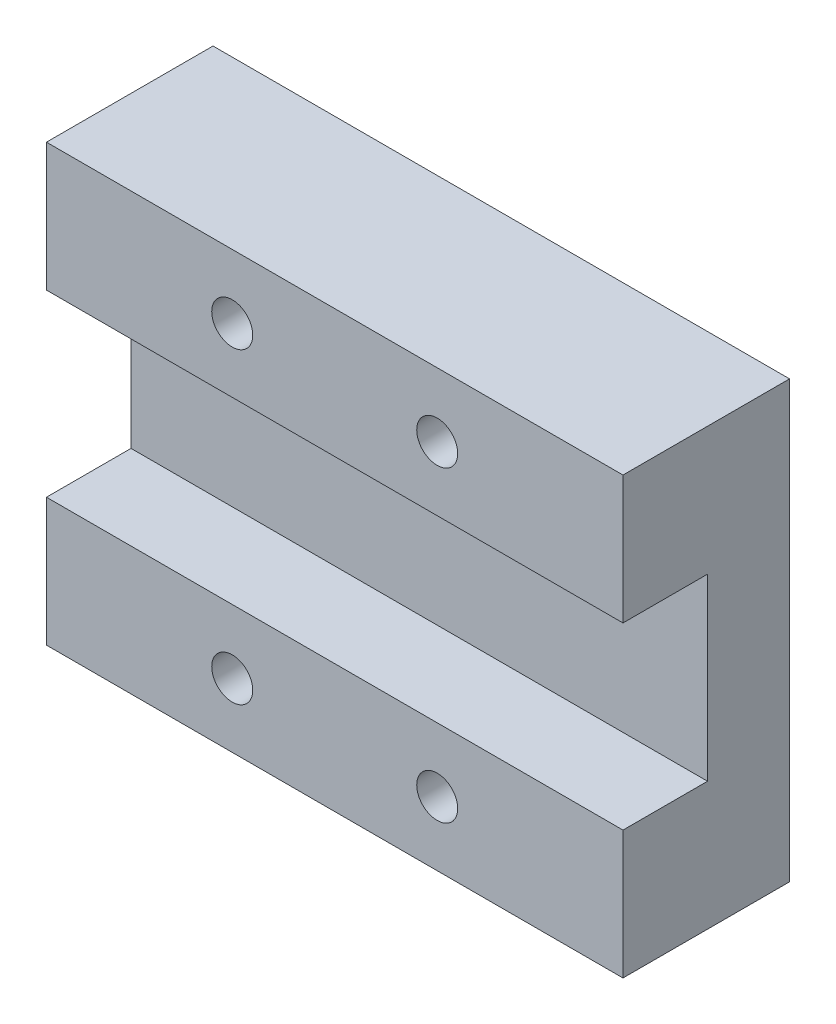
from build123d import *

# Parameters (mm, degrees)
SKETCH_1_W             = 22.5
SKETCH_1_H             = 17
EXTRUDE_1_DEPTH        = 6.5
SKETCH_2_W             = 3.3
SKETCH_2_H             = 7
CUT_EXTRUDE_1_DEPTH    = 23.5
HOLE_WIZARD_M2_1_D     = 1.6
HOLE_WIZARD_M2_1_DEPTH = 10.1
HOLE_WIZARD_M2_1_TIP   = 0.480688495


with BuildPart() as part:
    # 草图1 → 凸台-拉伸1 (new body)
    with BuildSketch(Plane.XY):
        with Locations((11.25, 8.5)):
            Rectangle(SKETCH_1_W, SKETCH_1_H)
    extrude(amount=EXTRUDE_1_DEPTH)

    # 草图2 → 切除-拉伸1 (cut, through all)
    with BuildSketch(Plane.ZY):
        with Locations((4.85, 8.5)):
            Rectangle(SKETCH_2_W, SKETCH_2_H)
    extrude(amount=-CUT_EXTRUDE_1_DEPTH, mode=Mode.SUBTRACT)

    # M2 螺纹孔1
    with Locations(Plane(origin=(0, 0, 0), x_dir=(-1, 0, 0), z_dir=(0, 0, -1))):
        with Locations((-15.25, 2.5), (-7.25, 2.5), (-15.25, 14.5), (-7.25, 14.5)):
            Hole(HOLE_WIZARD_M2_1_D / 2, depth=HOLE_WIZARD_M2_1_DEPTH)
            with Locations((0, 0, -(HOLE_WIZARD_M2_1_DEPTH + HOLE_WIZARD_M2_1_TIP / 2))):  # 118° drill point
                Cone(0, HOLE_WIZARD_M2_1_D / 2, HOLE_WIZARD_M2_1_TIP, mode=Mode.SUBTRACT)


solid = part.part
